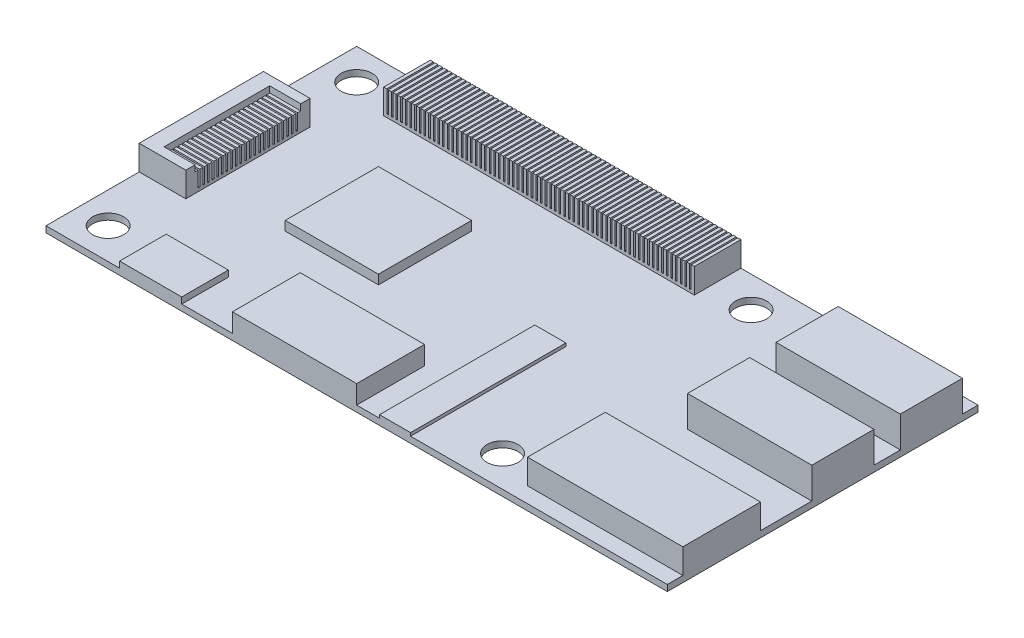
from build123d import *

# Parameters (mm, degrees)
SKETCH1_W            = 20
SKETCH1_H            = 10
SKETCH1_R            = 0.5
BOSS_EXTRUDE10_DEPTH = 0.2
SKETCH1_5_W          = 4
SKETCH1_5_H          = 2
BOSS_EXTRUDE11_DEPTH = 1
SKETCH1_6_W          = 5
SKETCH1_6_H          = 2.5
BOSS_EXTRUDE12_DEPTH = 0.8
SKETCH1_7_W          = 1.5
SKETCH1_7_H          = 4
SKETCH1_7_W_2        = 1
SKETCH1_7_H_2        = 5
SKETCH1_7_W_3        = 10
SKETCH1_7_H_3        = 1.5
BOSS_EXTRUDE13_DEPTH = 0.1
SKETCH1_8_W          = 2
SKETCH1_8_H          = 1.5
BOSS_EXTRUDE14_DEPTH = 0.2
SKETCH1_9_W          = 4
SKETCH1_9_H          = 2.182705629
BOSS_EXTRUDE15_DEPTH = 0.6
SKETCH3_W            = 0.1
SKETCH3_H            = 1.5
BOSS_EXTRUDE16_DEPTH = 0.7
LPATTERN1_COUNT      = 67
LPATTERN1_PITCH      = 0.15
BOSS_EXTRUDE17_DEPTH = 0.7
SKETCH5_W            = 1
SKETCH5_H            = 0.1
BOSS_EXTRUDE18_DEPTH = 0.5
LPATTERN2_COUNT      = 23
LPATTERN2_PITCH      = 0.15
SKETCH6_W            = 3
SKETCH6_H            = 3
BOSS_EXTRUDE19_DEPTH = 0.3


with BuildPart() as part:
    # Sketch1 → Boss-Extrude10 (new body)
    with BuildSketch(Plane(origin=(0, 0, 0), x_dir=(1, 0, 0), z_dir=(0, 1, 0))):
        Rectangle(SKETCH1_W, SKETCH1_H)
        with Locations((-9, -4)):
            Circle(SKETCH1_R, mode=Mode.SUBTRACT)
        with Locations((-9, 4)):
            Circle(SKETCH1_R, mode=Mode.SUBTRACT)
        with Locations((3.695159955, -4)):
            Circle(SKETCH1_R, mode=Mode.SUBTRACT)
        with Locations((3.695159955, 4)):
            Circle(SKETCH1_R, mode=Mode.SUBTRACT)
    extrude(amount=-BOSS_EXTRUDE10_DEPTH)

    # Sketch1_5 → Boss-Extrude11 (add)
    with BuildSketch(Plane(origin=(0, 0, 0), x_dir=(1, 0, 0), z_dir=(0, 1, 0))):
        with Locations((8, 0.65)):
            Rectangle(SKETCH1_5_W, SKETCH1_5_H)
        with Locations((8, 3.5)):
            Rectangle(SKETCH1_5_W, SKETCH1_5_H)
    extrude(amount=BOSS_EXTRUDE11_DEPTH)

    # Sketch1_6 → Boss-Extrude12 (add)
    with BuildSketch(Plane(origin=(0, 0, 0), x_dir=(1, 0, 0), z_dir=(0, 1, 0))):
        with Locations((7.5, -3.25)):
            Rectangle(SKETCH1_6_W, SKETCH1_6_H)
    extrude(amount=BOSS_EXTRUDE12_DEPTH)

    # Sketch1_7 → Boss-Extrude13 (add)
    with BuildSketch(Plane(origin=(0, 0, 0), x_dir=(1, 0, 0), z_dir=(0, 1, 0))):
        with Locations((-9.25, 0)):
            Rectangle(SKETCH1_7_W, SKETCH1_7_H)
        with Locations((1.234573767, -2.5)):
            Rectangle(SKETCH1_7_W_2, SKETCH1_7_H_2)
        with Locations((-2.631035222, 4.25)):
            Rectangle(SKETCH1_7_W_3, SKETCH1_7_H_3)
    extrude(amount=BOSS_EXTRUDE13_DEPTH)

    # Sketch1_8 → Boss-Extrude14 (add)
    with BuildSketch(Plane(origin=(0, 0, 0), x_dir=(1, 0, 0), z_dir=(0, 1, 0))):
        with Locations((-6.631035222, -4.25)):
            Rectangle(SKETCH1_8_W, SKETCH1_8_H)
    extrude(amount=BOSS_EXTRUDE14_DEPTH)

    # Sketch1_9 → Boss-Extrude15 (add)
    with BuildSketch(Plane(origin=(0, 0, 0), x_dir=(1, 0, 0), z_dir=(0, 1, 0))):
        with Locations((-2, -3.908647186)):
            Rectangle(SKETCH1_9_W, SKETCH1_9_H)
    extrude(amount=BOSS_EXTRUDE15_DEPTH)

    # Sketch3 → Boss-Extrude16 (add)
    with BuildSketch(Plane(origin=(0, 0.1, 0), x_dir=(1, 0, 0), z_dir=(0, 1, 0))):
        with Locations((-7.581035222, 4.25)):
            Rectangle(SKETCH3_W, SKETCH3_H)
    boss_extrude16 = extrude(amount=BOSS_EXTRUDE16_DEPTH)

    # LPattern1: Boss-Extrude16 ×67
    with Locations(*[(i * LPATTERN1_PITCH, 0, 0) for i in range(1, LPATTERN1_COUNT)]):
        add(boss_extrude16)

    # Sketch4 → Boss-Extrude17 (add)
    with BuildSketch(Plane(origin=(0, 0.1, 0), x_dir=(1, 0, 0), z_dir=(0, 1, 0))):
        Polygon((-8.5, 1.7), (-9.5, 1.7), (-9.5, -1.7), (-8.5, -1.7), (-8.5, -2), (-10, -2), (-10, 2), (-8.5, 2), align=None)
    extrude(amount=BOSS_EXTRUDE17_DEPTH)

    # Sketch5 → Boss-Extrude18 (add)
    with BuildSketch(Plane(origin=(0, 0.1, 0), x_dir=(1, 0, 0), z_dir=(0, 1, 0))):
        with Locations((-9, 1.65)):
            Rectangle(SKETCH5_W, SKETCH5_H)
    boss_extrude18 = extrude(amount=BOSS_EXTRUDE18_DEPTH)

    # LPattern2: Boss-Extrude18 ×23
    with Locations(*[(0, 0, i * LPATTERN2_PITCH) for i in range(1, LPATTERN2_COUNT)]):
        add(boss_extrude18)

    # Sketch6 → Boss-Extrude19 (add)
    with BuildSketch(Plane(origin=(0, 0, 0), x_dir=(1, 0, 0), z_dir=(0, 1, 0))):
        with Locations((-4.5, 0.2)):
            Rectangle(SKETCH6_W, SKETCH6_H)
    extrude(amount=BOSS_EXTRUDE19_DEPTH)


solid = part.part
